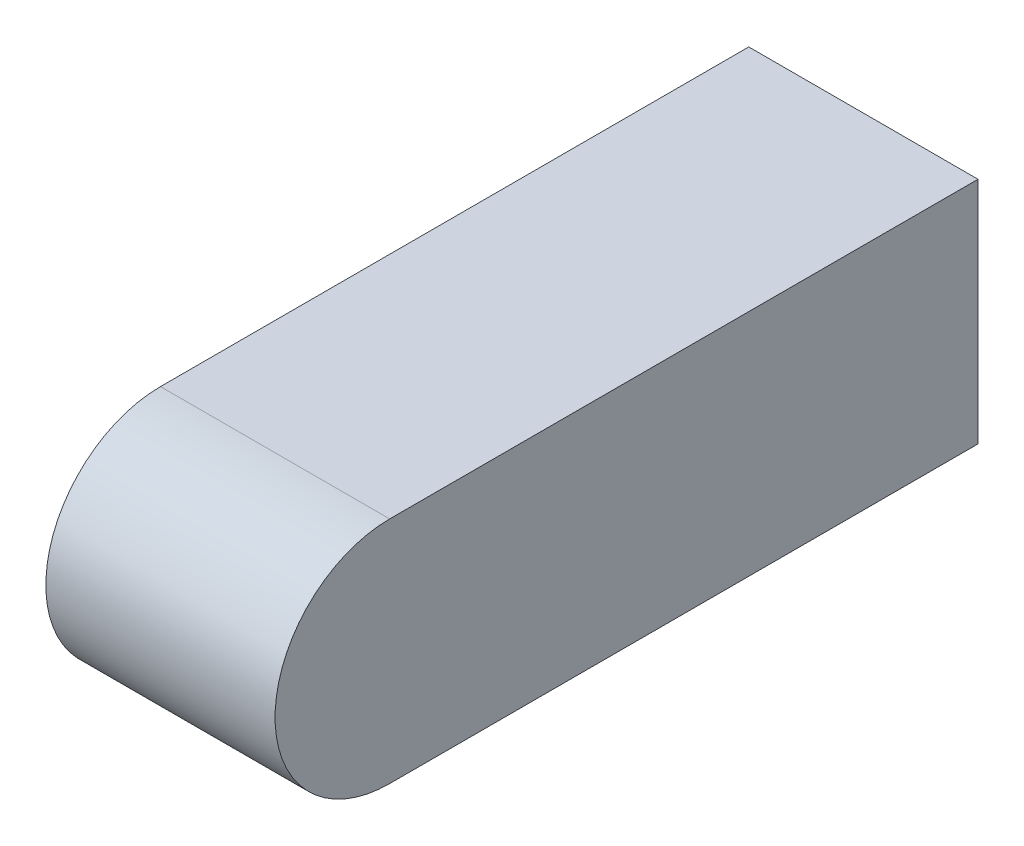
from build123d import *

# Parameters (mm, degrees)
SKETCH1_W               = 45
SKETCH1_H               = 45
BOSS_EXTRUDE1_DEPTH     = 138
CUT_EXTRUDE1_DEPTH      = 23.5
CUT_EXTRUDE1_DEPTH_BACK = 23.5


with BuildPart() as part:
    # Sketch1 → Boss-Extrude1 (new body)
    with BuildSketch(Plane.XY):
        Rectangle(SKETCH1_W, SKETCH1_H)
    extrude(amount=BOSS_EXTRUDE1_DEPTH)

    # Sketch2 → Cut-Extrude1 (cut, two sides)
    with BuildSketch(Plane(origin=(0, 0, 0), x_dir=(0, 0, -1), z_dir=(1, 0, 0))) as cut_extrude1_sk:
        with BuildLine():
            Line((-138, 22.5), (-138, 0))
            ThreePointArc((-138, 0), (-131.409902577, 15.909902577), (-115.5, 22.5))
            Line((-115.5, 22.5), (-138, 22.5))
        make_face()
        with BuildLine():
            Line((-138, -22.5), (-115.5, -22.5))
            ThreePointArc((-115.5, -22.5), (-131.409902577, -15.909902577), (-138, 0))
            Line((-138, 0), (-138, -22.5))
        make_face()
    extrude(amount=CUT_EXTRUDE1_DEPTH, mode=Mode.SUBTRACT)
    extrude(cut_extrude1_sk.sketch, amount=-CUT_EXTRUDE1_DEPTH_BACK, mode=Mode.SUBTRACT)


solid = part.part
